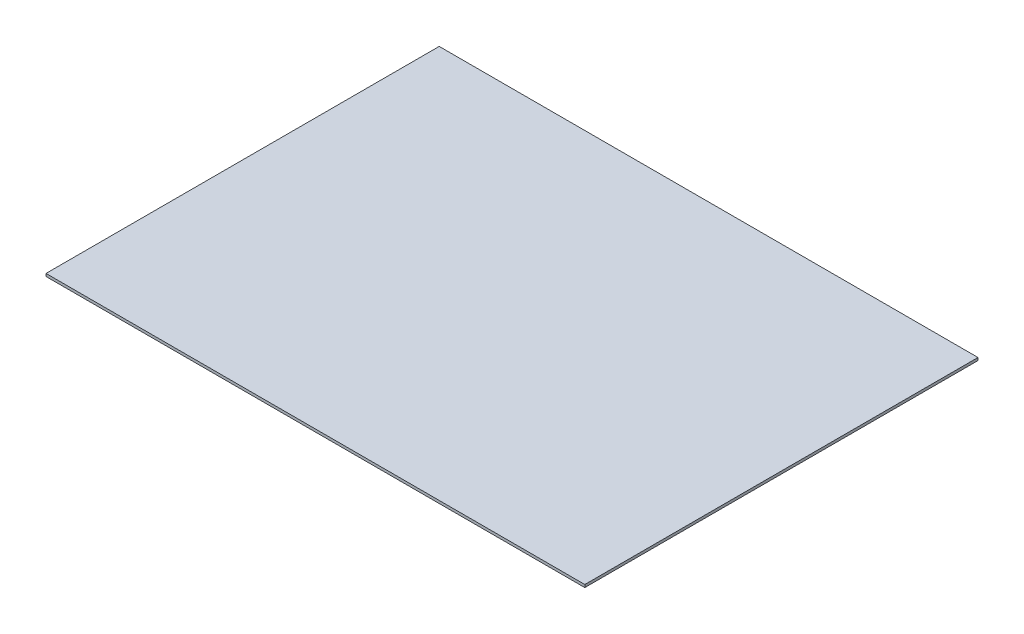
from build123d import *

# Parameters (mm, degrees)
SKETCH1_W           = 401.790647078
SKETCH1_H           = 293.21275681
BOSS_EXTRUDE1_DEPTH = 2


with BuildPart() as part:
    # Sketch1 → Boss-Extrude1 (new body)
    with BuildSketch(Plane(origin=(0, 0, 0), x_dir=(1, 0, 0), z_dir=(0, 1, 0))):
        Rectangle(SKETCH1_W, SKETCH1_H)
    extrude(amount=BOSS_EXTRUDE1_DEPTH)


solid = part.part
